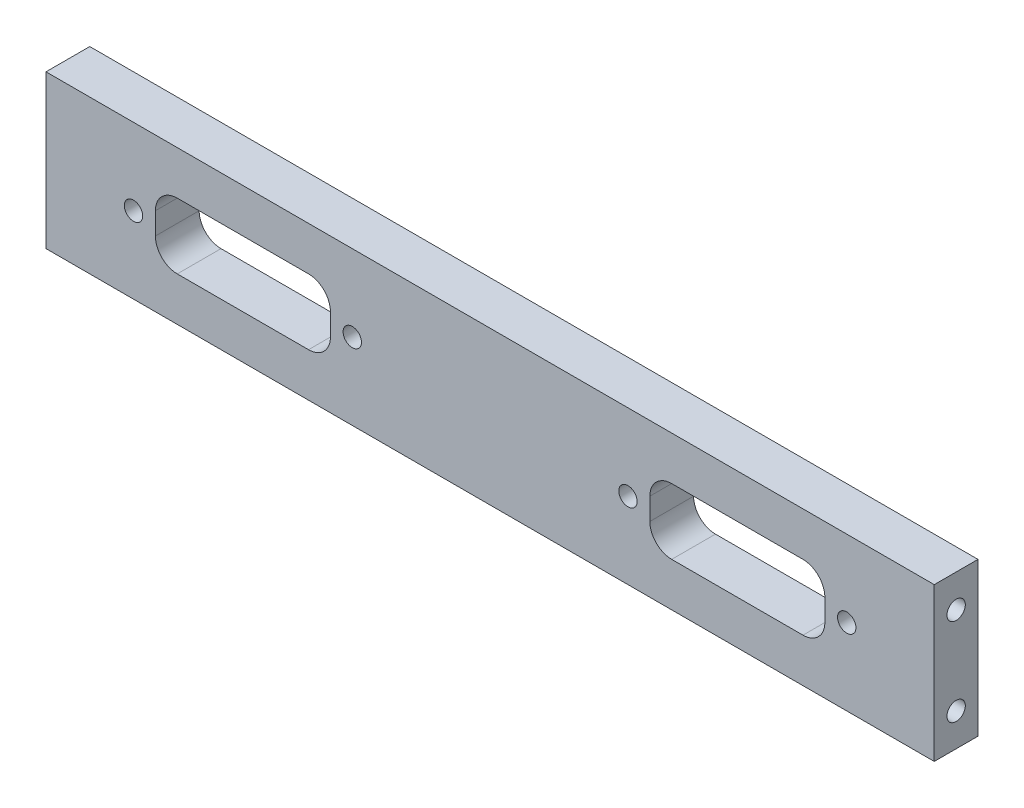
from build123d import *

# Parameters (mm, degrees)
SKETCH_1_W                  = 203
SKETCH_1_H                  = 35
EXTRUDE_1_DEPTH             = 5
HOLE_WIZARD_M5_1_AT_2_COUNT = 2
HOLE_WIZARD_M5_1_AT_2_PITCH = 20
SKETCH_4_W                  = 40
SKETCH_4_H                  = 15
CUT_EXTRUDE_1_DEPTH         = 10
FILLET_1_R                  = 5
HOLE_WIZARD_4_2_4_2_1_D     = 4.2
FILLET_1_OF_MIRROR_2_R      = 5


with BuildPart() as part:
    # 草图1 → 凸台-拉伸1 (new body, symmetric)
    with BuildSketch(Plane.XY):
        Rectangle(SKETCH_1_W, SKETCH_1_H)
    extrude(amount=EXTRUDE_1_DEPTH, both=True)

    # 草图2 → M5 螺纹孔1 (revolve, cut)
    with BuildSketch(Plane(origin=(-101.5, 10, 0), x_dir=(0, 0, 1), z_dir=(0, 1, 0))):
        Polygon((0, 0), (0, 15.2618073), (2.1, 14), (2.1, 0), align=None)
    hole_wizard_m5_1 = revolve(axis=Axis((-107.85, 10, 0), (1, 0, 0)), mode=Mode.SUBTRACT)

    # M5 螺纹孔1 at 2: M5 螺纹孔1 ×2
    with Locations(*[(0, -i * HOLE_WIZARD_M5_1_AT_2_PITCH, 0) for i in range(1, HOLE_WIZARD_M5_1_AT_2_COUNT)]):
        add(hole_wizard_m5_1, mode=Mode.SUBTRACT)

    # 镜向1: M5 螺纹孔1 across plane
    add(hole_wizard_m5_1.mirror(Plane(origin=(0, 0, 0), x_dir=(0, 0, 1), z_dir=(1, 0, 0))), mode=Mode.SUBTRACT)

    # 镜向1 copy 1 sketch → 镜向1 copy 1 (revolve, cut)
    with BuildSketch(Plane(origin=(101.5, -10, 0), x_dir=(0, 0, 1), z_dir=(0, 1, 0))):
        Polygon((0, 0), (0, -15.2618073), (2.1, -14), (2.1, 0), align=None)
    revolve(axis=Axis((107.85, -10, 0), (1, 0, 0)), mode=Mode.SUBTRACT)

    # 草图4 → 切除-拉伸1 (cut)
    with BuildSketch(Plane(origin=(0, 0, -5), x_dir=(-1, 0, 0), z_dir=(0, 0, -1))):
        with Locations((56.5, 0)):
            Rectangle(SKETCH_4_W, SKETCH_4_H)
    cut_extrude_1 = extrude(amount=-CUT_EXTRUDE_1_DEPTH, mode=Mode.SUBTRACT)

    # 圆角1
    fillet_1_edges = [part.edges().sort_by_distance(p)[0] for p in [
        (-76.5, 7.5, 0),
        (-76.5, -7.5, 0),
        (-36.5, -7.5, 0),
        (-36.5, 7.5, 0),
    ]]
    fillet(fillet_1_edges, radius=FILLET_1_R)

    # Ø4.2 (4.2) 直径孔1 (through all)
    with Locations(Plane(origin=(0, 0, -5), x_dir=(-1, 0, 0), z_dir=(0, 0, -1))):
        with Locations((81.5, 0), (31.5, 0)):
            hole_wizard_4_2_4_2_1 = Hole(HOLE_WIZARD_4_2_4_2_1_D / 2)

    # 镜向2: 切除-拉伸1, Ø4.2 (4.2) 直径孔1 across plane
    add(cut_extrude_1.mirror(Plane(origin=(0, 0, 0), x_dir=(0, 0, 1), z_dir=(1, 0, 0))), mode=Mode.SUBTRACT)
    add(hole_wizard_4_2_4_2_1.mirror(Plane(origin=(0, 0, 0), x_dir=(0, 0, 1), z_dir=(1, 0, 0))), mode=Mode.SUBTRACT)

    # 圆角1 of 镜向2
    fillet_1_of_mirror_2_edges = [part.edges().sort_by_distance(p)[0] for p in [
        (76.5, 7.5, 0),
        (76.5, -7.5, 0),
        (36.5, -7.5, 0),
        (36.5, 7.5, 0),
    ]]
    fillet(fillet_1_of_mirror_2_edges, radius=FILLET_1_OF_MIRROR_2_R)


solid = part.part
